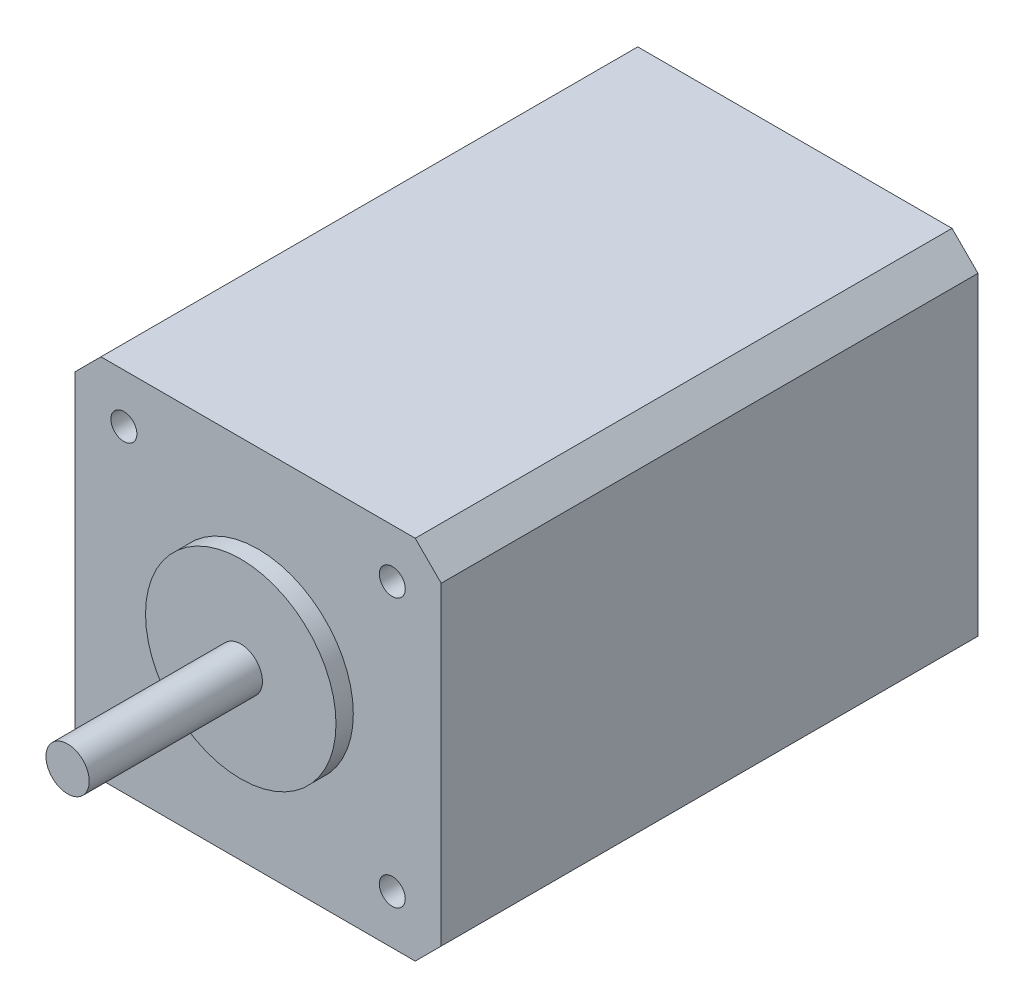
from build123d import *

# Parameters (mm, degrees)
SKETCH_1_W          = 42.3
SKETCH_1_H          = 42.3
EXTRUDE_1_DEPTH     = 62
SKETCH_2_R          = 11
EXTRUDE_2_DEPTH     = 2
SKETCH_3_R          = 2.5
EXTRUDE_3_DEPTH     = 20
CHAMFER_1_SIZE      = 3
SKETCH_4_R          = 1.5
CUT_EXTRUDE_1_DEPTH = 10


with BuildPart() as part:
    # 草图1 → 凸台-拉伸1 (new body)
    with BuildSketch(Plane.XY):
        Rectangle(SKETCH_1_W, SKETCH_1_H)
    extrude(amount=EXTRUDE_1_DEPTH)

    # 草图2 → 凸台-拉伸2 (add)
    with BuildSketch(Plane.XY.offset(62)):
        Circle(SKETCH_2_R)
    extrude(amount=EXTRUDE_2_DEPTH)

    # 草图3 → 凸台-拉伸3 (add)
    with BuildSketch(Plane.XY.offset(64)):
        Circle(SKETCH_3_R)
    extrude(amount=EXTRUDE_3_DEPTH)

    # 倒角1
    chamfer_1_edges = [part.edges().sort_by_distance(p)[0] for p in [
        (21.15, -21.15, 31),
        (-21.15, -21.15, 31),
        (-21.15, 21.15, 31),
        (21.15, 21.15, 31),
    ]]
    chamfer(chamfer_1_edges, length=CHAMFER_1_SIZE)

    # 草图4 → 切除-拉伸1 (cut)
    with BuildSketch(Plane.XY.offset(62)):
        with Locations((15.5, -15.5)):
            Circle(SKETCH_4_R)
        with Locations((-15.5, -15.5)):
            Circle(SKETCH_4_R)
        with Locations((15.5, 15.5)):
            Circle(SKETCH_4_R)
        with Locations((-15.5, 15.5)):
            Circle(SKETCH_4_R)
    extrude(amount=-CUT_EXTRUDE_1_DEPTH, mode=Mode.SUBTRACT)


solid = part.part
